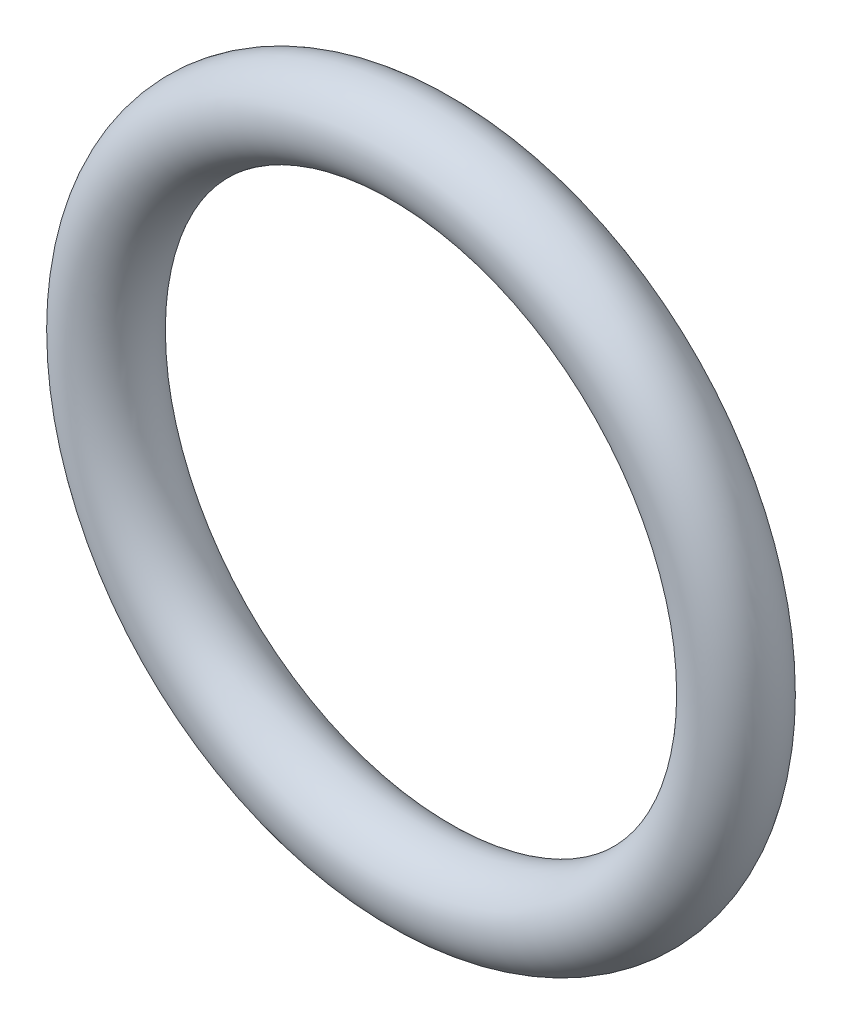
from build123d import *

# Parameters (mm, degrees)
SKETCH2_R = 0.5


with BuildPart() as part:
    # Sketch2 → Revolve1 (revolve)
    with BuildSketch(Plane(origin=(0, 0, 0), x_dir=(1, 0, 0), z_dir=(0, 1, 0))):
        with Locations((3.75, 0)):
            Circle(SKETCH2_R)
    revolve(axis=Axis((0, 0, -0.5), (0, 0, 1)))


solid = part.part
